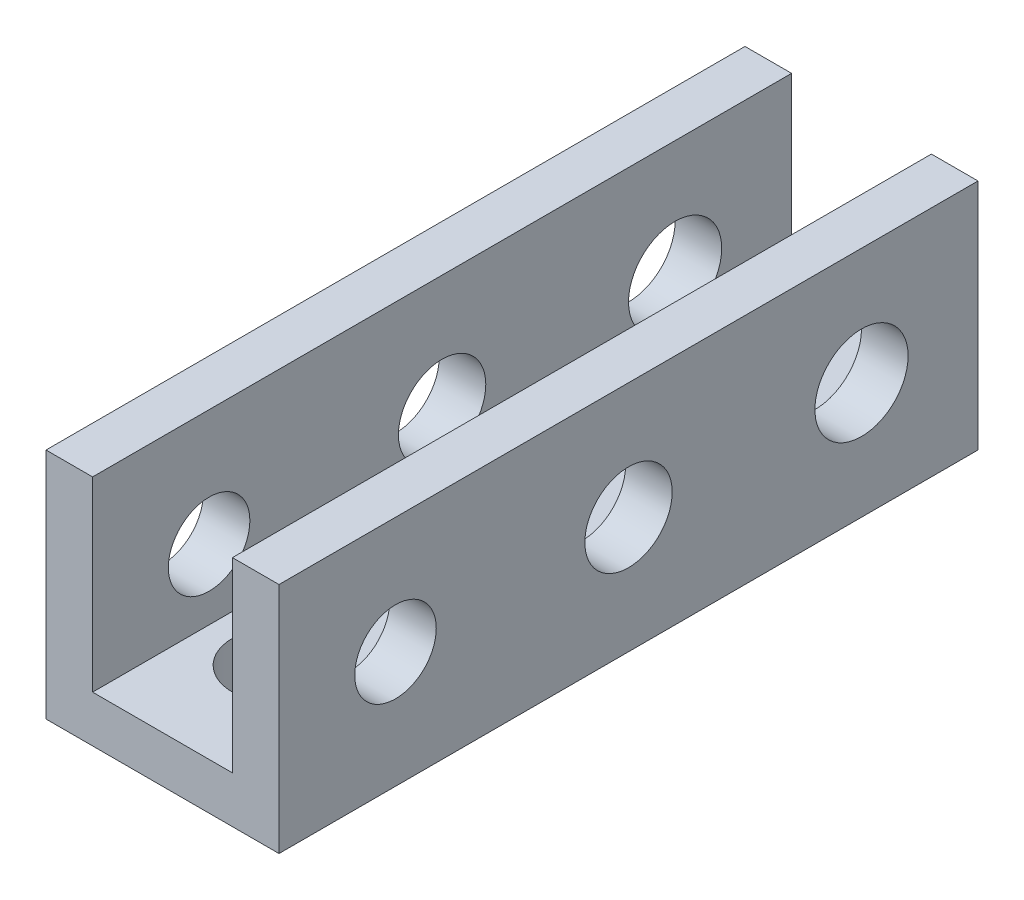
from build123d import *

# Parameters (mm, degrees)
BOSS_EXTRUDE1_DEPTH     = 30
SKETCH2_R               = 1.75
SKETCH2_R_2             = 2
SKETCH2_R_3             = 1.875
CUT_EXTRUDE2_DEPTH      = 9
CUT_EXTRUDE2_DEPTH_BACK = 3
SKETCH3_R               = 1.75
SKETCH3_R_2             = 1.875
SKETCH3_R_3             = 2
CUT_EXTRUDE3_DEPTH      = 10


with BuildPart() as part:
    # Sketch1 → Boss-Extrude1 (new body)
    with BuildSketch(Plane.XY):
        Polygon((3, 1), (-3, 1), (-3, 9), (-5, 9), (-5, -1), (5, -1), (5, 9), (3, 9), align=None)
    extrude(amount=BOSS_EXTRUDE1_DEPTH)

    # Sketch2 → Cut-Extrude2 (cut, two sides)
    with BuildSketch(Plane(origin=(-3, 0, 0), x_dir=(0, 0, -1), z_dir=(1, 0, 0))) as cut_extrude2_sk:
        with Locations((-25, 4)):
            Circle(SKETCH2_R)
        with Locations((-5, 4)):
            Circle(SKETCH2_R_2)
        with Locations((-15, 4)):
            Circle(SKETCH2_R_3)
    extrude(amount=CUT_EXTRUDE2_DEPTH, mode=Mode.SUBTRACT)
    extrude(cut_extrude2_sk.sketch, amount=-CUT_EXTRUDE2_DEPTH_BACK, mode=Mode.SUBTRACT)

    # Sketch3 → Cut-Extrude3 (cut)
    with BuildSketch(Plane(origin=(0, 1, 0), x_dir=(1, 0, 0), z_dir=(0, 1, 0))):
        with Locations((0, -5)):
            Circle(SKETCH3_R)
        with Locations((0, -15)):
            Circle(SKETCH3_R_2)
        with Locations((0, -25)):
            Circle(SKETCH3_R_3)
    extrude(amount=-CUT_EXTRUDE3_DEPTH, mode=Mode.SUBTRACT)


solid = part.part
